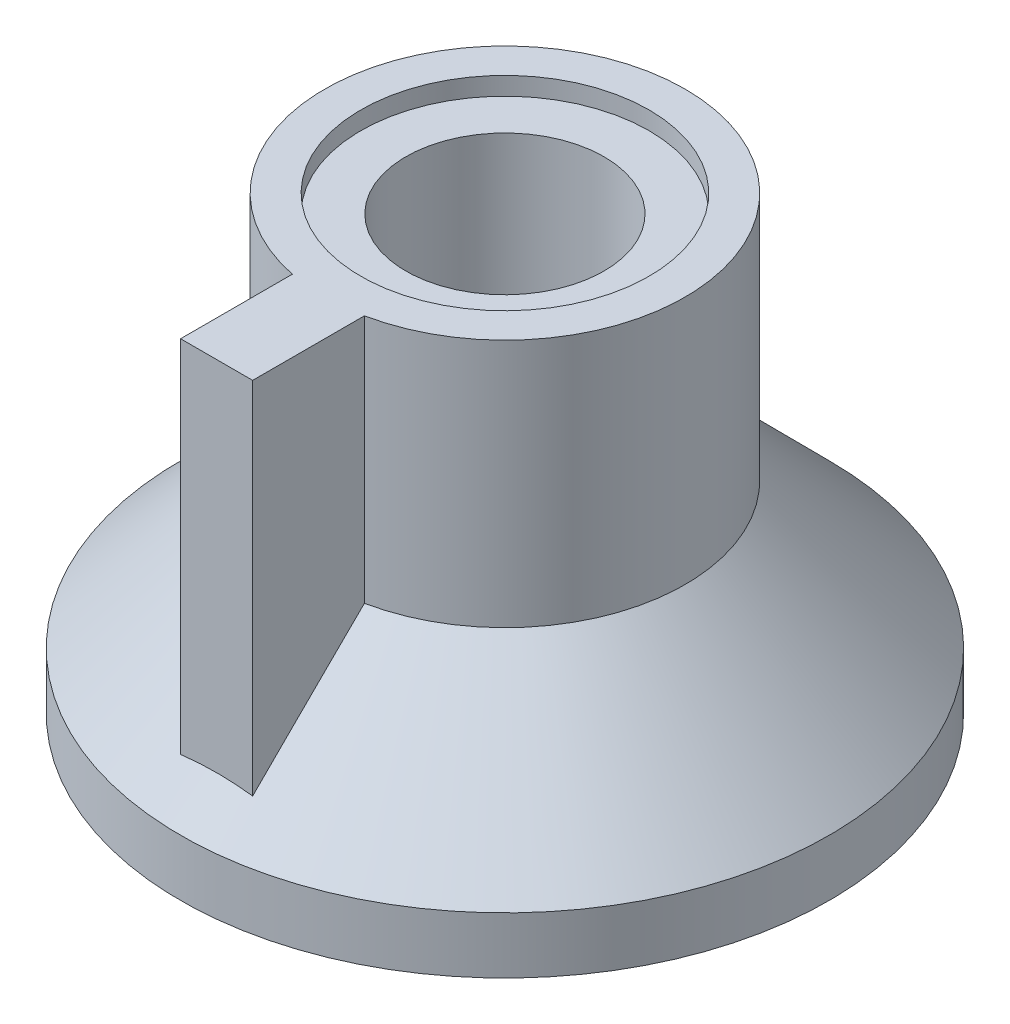
from build123d import *

# Parameters (mm, degrees)
SKETCH2_W           = 2
SKETCH2_H           = 12.5
BOSS_EXTRUDE1_DEPTH = 3.5
SKETCH3_W           = 6.040817985
SKETCH3_H           = 3.31390433


with BuildPart() as part:
    # Sketch1 → Revolve1 (revolve)
    with BuildSketch(Plane(origin=(0, 0, 0), x_dir=(0, 0, -1), z_dir=(1, 0, 0))):
        Polygon((-4, 14.088414634), (-4, 14.588414634), (-5, 14.588414634), (-5, 7.679878049), (-9, 3.655487805), (-9, 2.088414634), (-6, 2.088414634), (-6, 4.509146341), (-2.75, 4.509146341), (-2.75, 14.088414634), align=None)
    revolve(axis=Axis((0, 0, 0), (0, 1, 0)))

    # Sketch2 → Boss-Extrude1 (add)
    with BuildSketch(Plane.XY.offset(8)):
        with Locations((0, 8.338414634)):
            Rectangle(SKETCH2_W, SKETCH2_H)
    extrude(amount=-BOSS_EXTRUDE1_DEPTH)

    # Sketch3 → Cut-Revolve1 (revolve, cut)
    with BuildSketch(Plane(origin=(0, 0, 0), x_dir=(0, 0, -1), z_dir=(1, 0, 0))):
        with Locations((3.020408993, 2.852194176)):
            Rectangle(SKETCH3_W, SKETCH3_H)
    revolve(axis=Axis((0, 1.195242011, 0), (0, 1, 0)), mode=Mode.SUBTRACT)


solid = part.part
